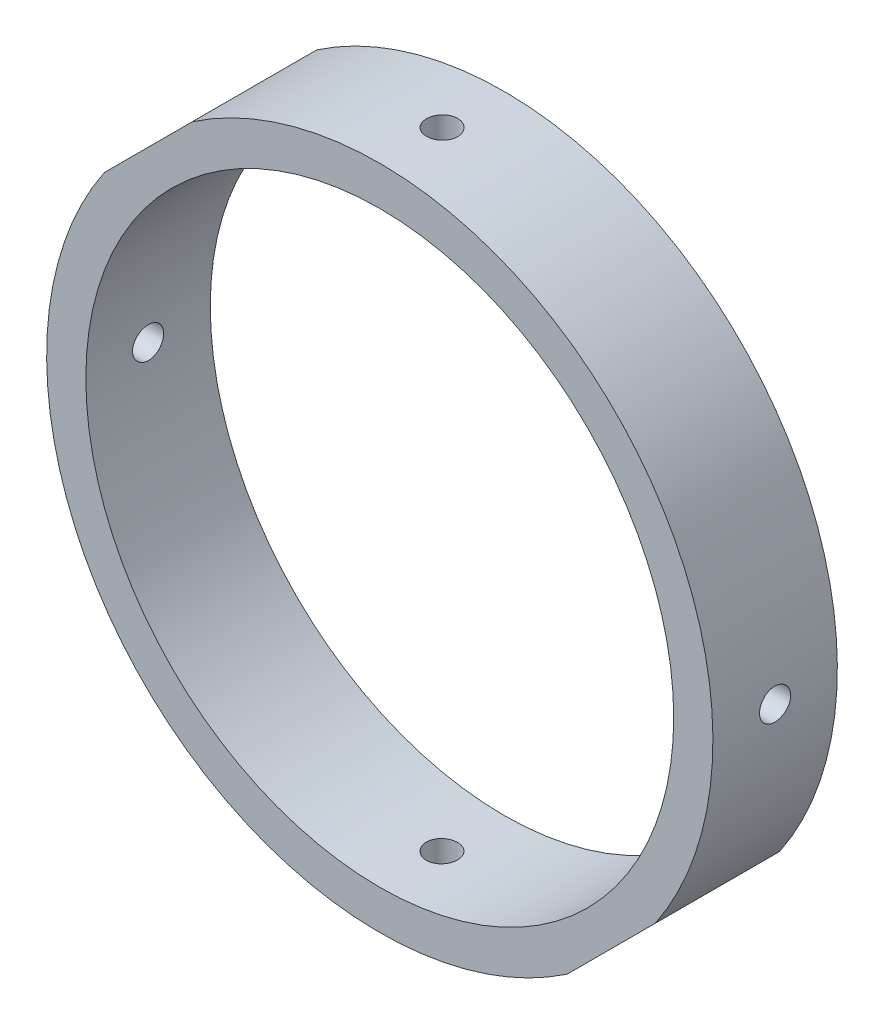
from build123d import *

# Parameters (mm, degrees)
SALIENTE_EXTRUIR1_DEPTH      = 6.35
SALIENTE_EXTRUIR1_DEPTH_BACK = 6.35
CROQUIS1_R                   = 30
CORTAR_EXTRUIR1_DEPTH        = 49.500747417
CORTAR_EXTRUIR1_DEPTH_BACK   = 49.500747417
CROQUIS3_R                   = 1.5875
CORTAR_EXTRUIR2_DEPTH        = 49.500747581
CORTAR_EXTRUIR2_DEPTH_BACK   = 49.500747581
CROQUIS4_R                   = 1.5875
CROQUIS5_R                   = 1.75
CORTAR_EXTRUIR3_DEPTH        = 82.732068501


with BuildPart() as part:
    # Croquis1 → Saliente-Extruir1 (new, two sides: drawn at the far end of the back side and taken through both)
    with BuildSketch(Plane.XY.offset(-SALIENTE_EXTRUIR1_DEPTH_BACK)):
        with BuildLine():
            Line((-19.128482186, 28.108738308), (-28.108738308, 19.128482186))
            ThreePointArc((-28.108738308, 19.128482186), (-24.04163056, -24.04163056), (19.128482186, -28.108738308))
            Line((19.128482186, -28.108738308), (28.108738308, -19.128482186))
            ThreePointArc((28.108738308, -19.128482186), (24.04163056, 24.04163056), (-19.128482186, 28.108738308))
        make_face()
        Circle(CROQUIS1_R, mode=Mode.SUBTRACT)
    extrude(amount=SALIENTE_EXTRUIR1_DEPTH + SALIENTE_EXTRUIR1_DEPTH_BACK)

    # Croquis3 → Cortar-Extruir1 (cut, two sides: drawn at the far end of the back side and taken through both)
    with BuildSketch(Plane(origin=(0, 0, 0), x_dir=(1, 0, 0), z_dir=(0, 1, 0)).offset(-CORTAR_EXTRUIR1_DEPTH_BACK)):
        Circle(CROQUIS3_R)
    extrude(amount=CORTAR_EXTRUIR1_DEPTH + CORTAR_EXTRUIR1_DEPTH_BACK, mode=Mode.SUBTRACT)

    # Croquis4 → Cortar-Extruir2 (cut, two sides: drawn at the far end of the back side and taken through both)
    with BuildSketch(Plane(origin=(0, 0, 0), x_dir=(0, 0, -1), z_dir=(1, 0, 0)).offset(-CORTAR_EXTRUIR2_DEPTH_BACK)):
        Circle(CROQUIS4_R)
    extrude(amount=CORTAR_EXTRUIR2_DEPTH + CORTAR_EXTRUIR2_DEPTH_BACK, mode=Mode.SUBTRACT)

    # Croquis5 → Cortar-Extruir3 (cut, through all)
    with BuildSketch(Plane(origin=(-23.618610247, 23.618610247, 0), x_dir=(0, 0, 1), z_dir=(-0.707106781186549, 0.707106781186546, 0))):
        with Locations((-3.5, 0)):
            Circle(CROQUIS5_R)
        with Locations((3.5, 0)):
            Circle(CROQUIS5_R)
    extrude(amount=-CORTAR_EXTRUIR3_DEPTH, mode=Mode.SUBTRACT)


solid = part.part
